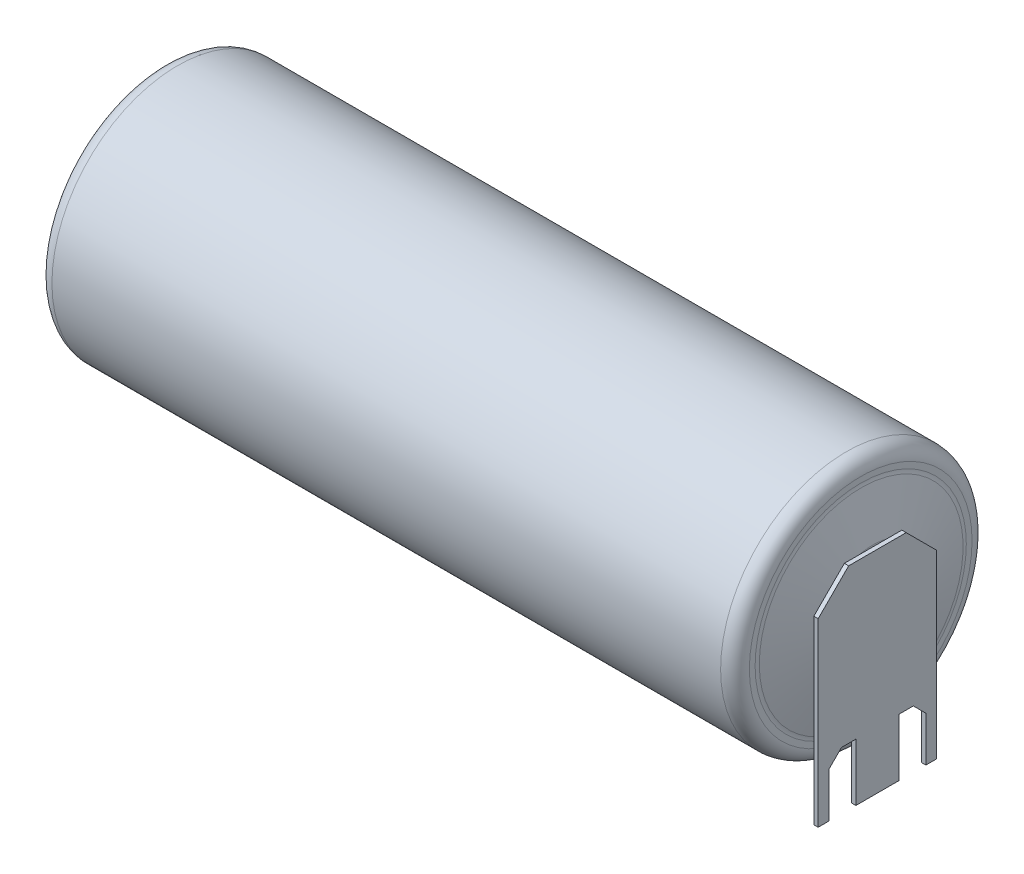
from build123d import *

# Parameters (mm, degrees)
BOSS_EXTRUDE1_DEPTH = 0.3
SKETCH3_W           = 3
SKETCH3_H           = 13
BOSS_EXTRUDE2_DEPTH = 0.3


with BuildPart() as part:
    # Sketch1 → Revolve1 (revolve)
    with BuildSketch(Plane.XY):
        with BuildLine():
            Line((-25.5, 0), (24.7, 0))
            Line((24.7, 0), (24.7, 0.7))
            ThreePointArc((24.7, 0.7), (24.729289322, 0.770710678), (24.8, 0.8))
            Line((24.8, 0.8), (25.4, 0.8))
            ThreePointArc((25.4, 0.8), (25.470710678, 0.829289322), (25.5, 0.9))
            Line((25.5, 0.9), (25.5, 3.947339001))
            ThreePointArc((25.5, 3.947339001), (25.496577945, 3.999549478), (25.486370331, 4.050866619))
            Line((25.486370331, 4.050866619), (24.671720559, 7.091180955))
            ThreePointArc((24.671720559, 7.091180955), (24.646201524, 7.219473808), (24.637646386, 7.35))
            Line((24.637646386, 7.35), (24.637646386, 7.75))
            ThreePointArc((24.637646386, 7.75), (24.344753167, 8.457106781), (23.637646386, 8.75))
            Line((23.637646386, 8.75), (-22.9, 8.75))
            ThreePointArc((-22.9, 8.75), (-23.607106781, 8.457106781), (-23.9, 7.75))
            Line((-23.9, 7.75), (-23.9, 6.85))
            ThreePointArc((-23.9, 6.85), (-23.870710678, 6.779289322), (-23.8, 6.75))
            Line((-23.8, 6.75), (-23.5, 6.75))
            ThreePointArc((-23.5, 6.75), (-23.429289322, 6.720710678), (-23.4, 6.65))
            Line((-23.4, 6.65), (-23.4, 4.35))
            ThreePointArc((-23.4, 4.35), (-23.429289322, 4.279289322), (-23.5, 4.25))
            Line((-23.5, 4.25), (-23.6, 4.25))
            ThreePointArc((-23.6, 4.25), (-23.670710678, 4.220710678), (-23.7, 4.15))
            Line((-23.7, 4.15), (-23.7, 2.9))
            ThreePointArc((-23.7, 2.9), (-23.817157288, 2.617157288), (-24.1, 2.5))
            Line((-24.1, 2.5), (-25.1, 2.5))
            ThreePointArc((-25.1, 2.5), (-25.382842712, 2.382842712), (-25.5, 2.1))
            Line((-25.5, 2.1), (-25.5, 0))
        make_face()
    revolve(axis=Axis((-25.5, 0, 0), (1, 0, 0)))

    # Sketch2 → Boss-Extrude1 (add)
    with BuildSketch(Plane(origin=(25.5, 0, 0), x_dir=(0, 0, -1), z_dir=(1, 0, 0))):
        Polygon((-2, 3.947339001), (2, 3.947339001), (4.125, 1.822339001), (4.125, -10.75), (3.375, -10.75), (3.375, -7.625), (2.5, -6.75), (1.5, -6.75), (1.5, -10.75), (-1.5, -10.75), (-1.5, -6.75), (-2.5, -6.75), (-3.375, -7.625), (-3.375, -10.75), (-4.125, -10.75), (-4.125, 1.822339001), align=None)
    extrude(amount=BOSS_EXTRUDE1_DEPTH)

    # Sketch3 → Boss-Extrude2 (add)
    with BuildSketch(Plane.ZY.offset(25.5)):
        with Locations((0, -4.25)):
            Rectangle(SKETCH3_W, SKETCH3_H)
    extrude(amount=BOSS_EXTRUDE2_DEPTH)


solid = part.part
